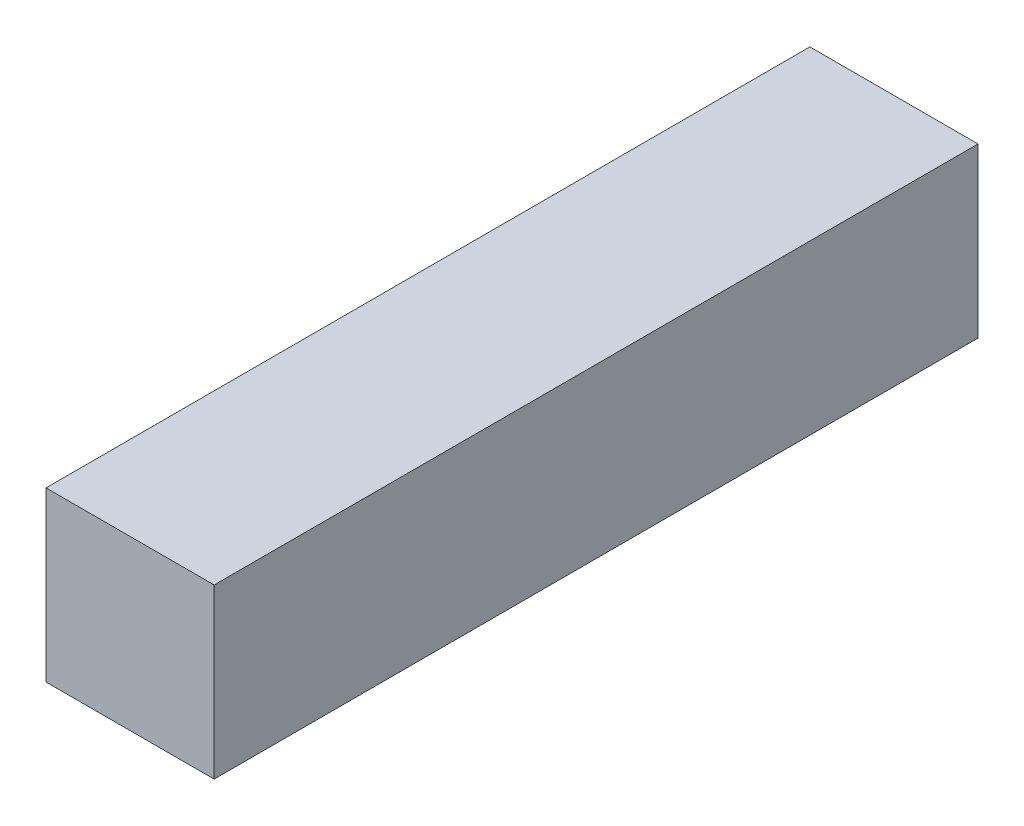
from build123d import *

# Parameters (mm, degrees)
SKETCH_1_W      = 7
SKETCH_1_H      = 7
EXTRUDE_1_DEPTH = 31.8


with BuildPart() as part:
    # Эскиз1 → Бобышка-Вытянуть1 (new body)
    with BuildSketch(Plane.XY):
        with Locations((-3.5, 3.5)):
            Rectangle(SKETCH_1_W, SKETCH_1_H)
    extrude(amount=-EXTRUDE_1_DEPTH)


solid = part.part
